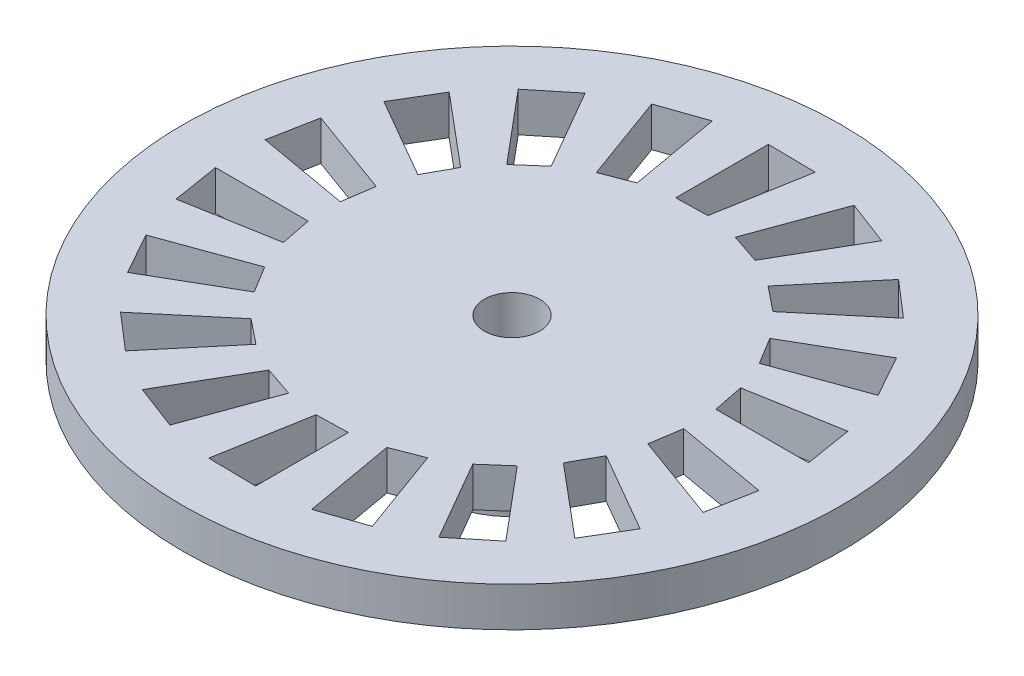
from build123d import *

# Parameters (mm, degrees)
SKETCH_1_R               = 12.5
EXTRUDE_1_DEPTH          = 1.5
CUT_EXTRUDE_1_DEPTH      = 2
SKETCH_3_R               = 1.05
CUT_EXTRUDE_2_DEPTH      = 22
EXTRUDE_START            = -1.5
SKETCH_4_R               = 3
EXTRUDE_2_DEPTH          = 3
PATTERN_CIRCULAR_1_COUNT = 18
SKETCH_5_R               = 1.05
CUT_EXTRUDE_3_DEPTH      = 23


with BuildPart() as part:
    # 스케치1 → 보스-돌출1 (new body)
    with BuildSketch(Plane(origin=(0, 0, 0), x_dir=(1, 0, 0), z_dir=(0, 1, 0))):
        Circle(SKETCH_1_R)
    extrude(amount=EXTRUDE_1_DEPTH)

    # 스케치2 → 컷-돌출1 (cut)
    with BuildSketch(Plane(origin=(0, 1.5, 0), x_dir=(1, 0, 0), z_dir=(0, 1, 0))):
        Polygon((-0.75, 6.959705454), (0.444838448, 6.985851326), (1.05510653, 10.446853603), (-0.75, 10.473180033), align=None)
    cut_extrude_1 = extrude(amount=-CUT_EXTRUDE_1_DEPTH, mode=Mode.SUBTRACT)

    # 스케치3 → 컷-돌출2 (cut)
    with BuildSketch(Plane(origin=(0, 1.5, 0), x_dir=(1, 0, 0), z_dir=(0, 1, 0))):
        Circle(SKETCH_3_R)
    extrude(amount=-CUT_EXTRUDE_2_DEPTH, mode=Mode.SUBTRACT)

    # 스케치4 → 보스-돌출2 (add)
    with BuildSketch(Plane(origin=(0, 1.5, 0), x_dir=(1, 0, 0), z_dir=(0, 1, 0)).offset(EXTRUDE_START)):
        Circle(SKETCH_4_R)
    extrude(amount=-EXTRUDE_2_DEPTH)

    # 원형 패턴1: 컷-돌출1 ×18 about axis
    pattern_circular_1_axis = Axis((0, 0, 0), (0, 1, 0))
    for i in range(1, PATTERN_CIRCULAR_1_COUNT):
        add(cut_extrude_1.rotate(pattern_circular_1_axis, i * 360 / PATTERN_CIRCULAR_1_COUNT), mode=Mode.SUBTRACT)

    # 스케치5 → 컷-돌출3 (cut)
    with BuildSketch(Plane(origin=(0, 1.5, 0), x_dir=(1, 0, 0), z_dir=(0, 1, 0))):
        Circle(SKETCH_5_R)
    extrude(amount=-CUT_EXTRUDE_3_DEPTH, mode=Mode.SUBTRACT)


solid = part.part
